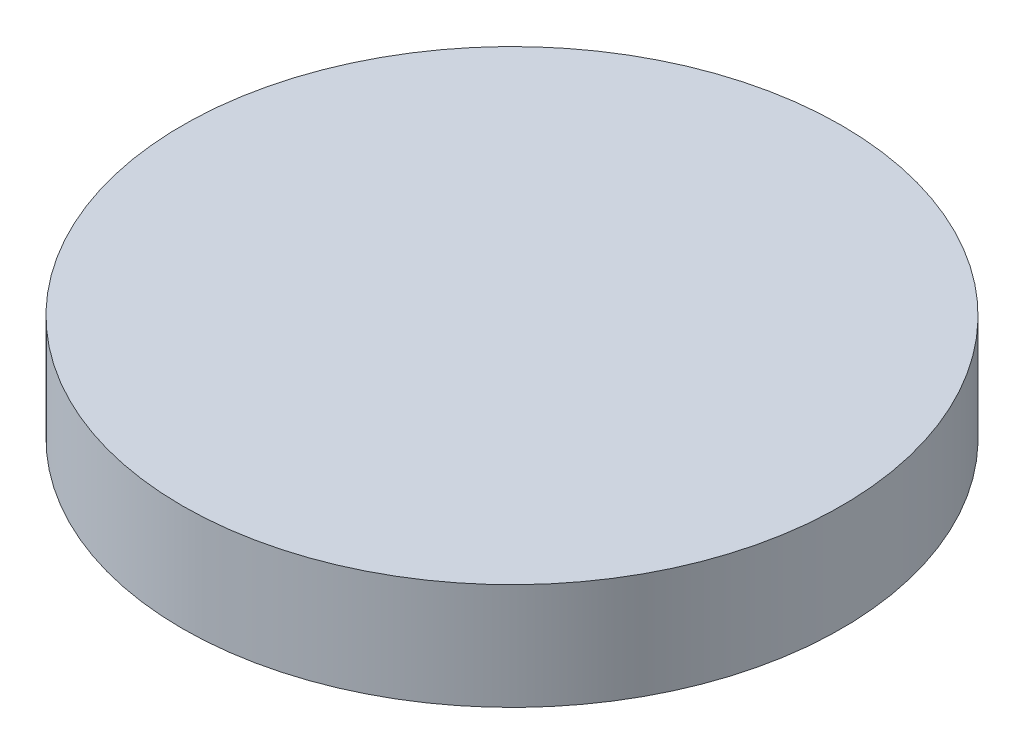
from build123d import *

# Parameters (mm, degrees)
SKETCH2_R             = 52.5
SKETCH2_R_2           = 47.5
BOSS_EXTRUDE1_DEPTH   = 20
SKETCH2_R_3           = 77.5
SKETCH2_R_4           = 72.5
BOSS_EXTRUDE1_2_DEPTH = 20
SKETCH3_R             = 77.5
BOSS_EXTRUDE2_DEPTH   = 5


with BuildPart() as part:
    # Sketch2 → Boss-Extrude1 (new body)
    with BuildSketch(Plane(origin=(0, 0, 0), x_dir=(1, 0, 0), z_dir=(0, 1, 0))):
        Circle(SKETCH2_R)
        Circle(SKETCH2_R_2, mode=Mode.SUBTRACT)
    extrude(amount=BOSS_EXTRUDE1_DEPTH)



with BuildPart() as body_2:
    # Sketch2 → Boss-Extrude1 2 (new body)
    with BuildSketch(Plane(origin=(0, 0, 0), x_dir=(1, 0, 0), z_dir=(0, 1, 0))):
        Circle(SKETCH2_R_3)
        Circle(SKETCH2_R_4, mode=Mode.SUBTRACT)
    extrude(amount=BOSS_EXTRUDE1_2_DEPTH)


with BuildPart() as part_1:
    add(part.part)

    add(body_2.part)  # Boss-Extrude2 merges body 2
    # Sketch3 → Boss-Extrude2 (add)
    with BuildSketch(Plane(origin=(0, 20, 0), x_dir=(1, 0, 0), z_dir=(0, 1, 0))):
        Circle(SKETCH3_R)
    extrude(amount=BOSS_EXTRUDE2_DEPTH)


solid = part_1.part
